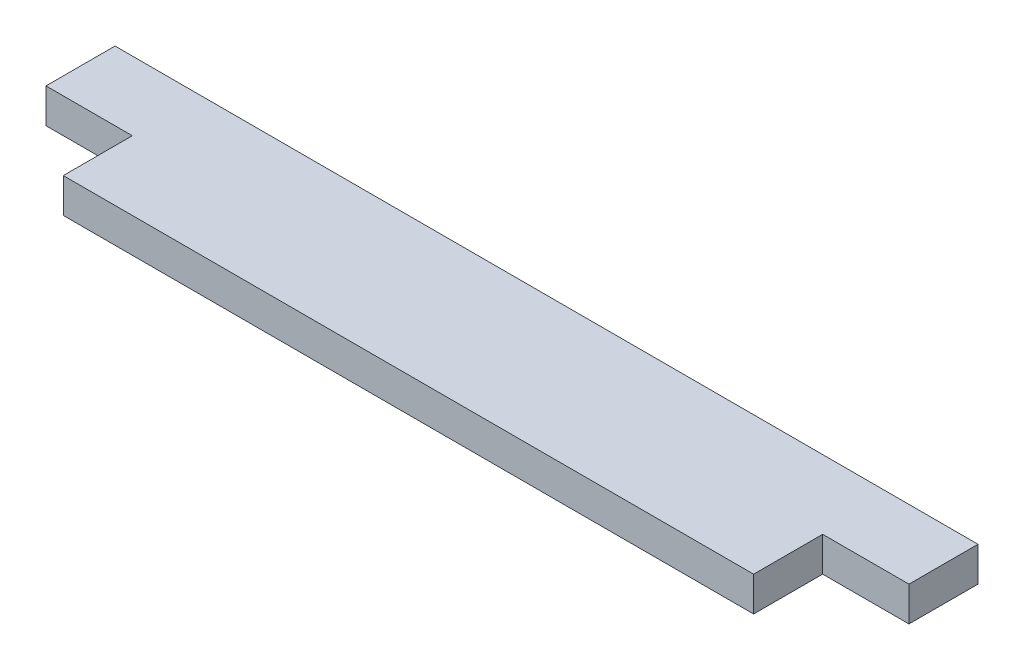
from build123d import *

# Parameters (mm, degrees)
SKETCH1_W           = 50
SKETCH1_H           = 4
SKETCH1_W_2         = 40
BOSS_EXTRUDE1_DEPTH = 2


with BuildPart() as part:
    # Sketch1 → Boss-Extrude1 (new body)
    with BuildSketch(Plane(origin=(0, 0, 0), x_dir=(1, 0, 0), z_dir=(0, 1, 0))):
        with Locations((17.74137931, -0.293103448)):
            Rectangle(SKETCH1_W, SKETCH1_H)
        with Locations((17.74137931, -4.293103448)):
            Rectangle(SKETCH1_W_2, SKETCH1_H)
    extrude(amount=BOSS_EXTRUDE1_DEPTH)


solid = part.part
